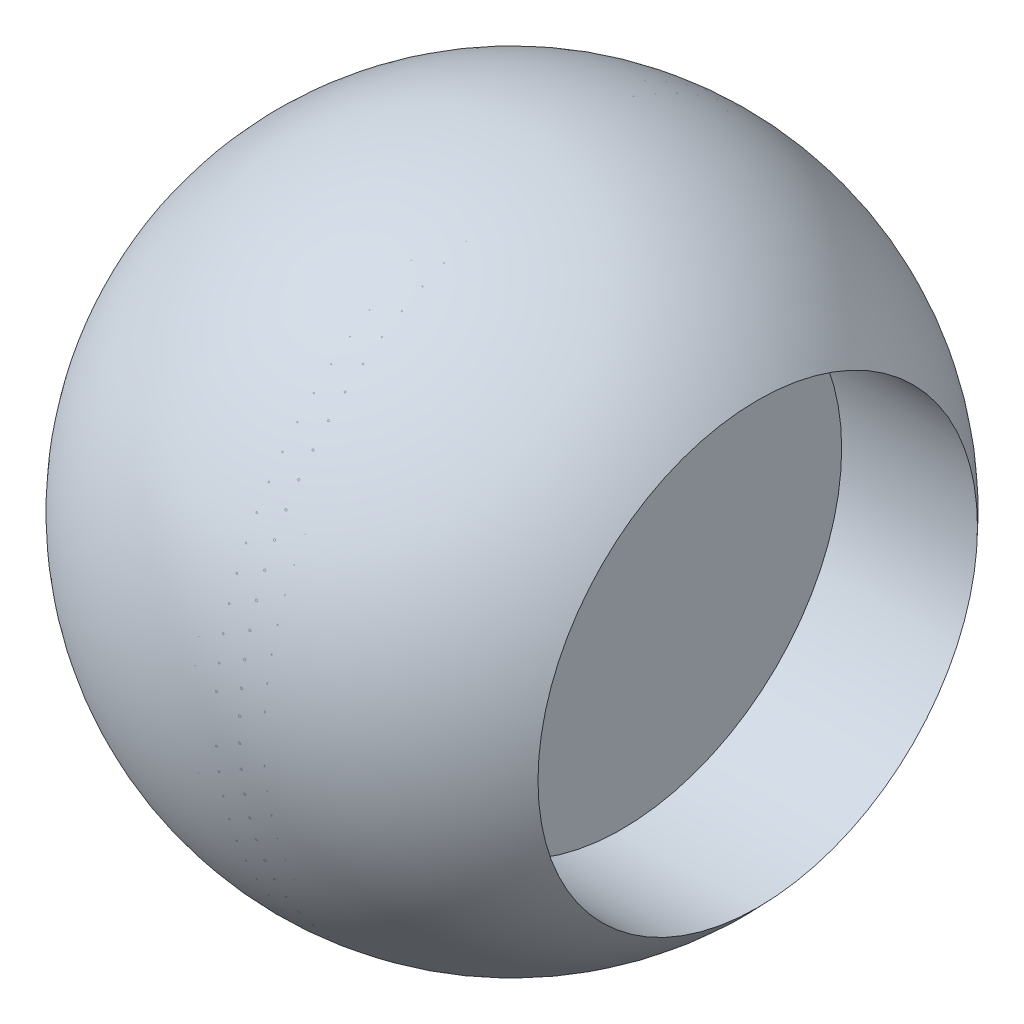
from build123d import *

# Parameters (mm, degrees)
SKETCH4_R          = 15
CUT_EXTRUDE1_DEPTH = 15


with BuildPart() as part:
    # Sketch1 → Revolve1 (revolve)
    with BuildSketch(Plane.XY):
        with BuildLine():
            Line((0, 22.5), (0, -22.5))
            ThreePointArc((0, -22.5), (22.5, 0), (0, 22.5))
        make_face()
    revolve(axis=Axis((0, 22.5, 0), (0, -1, 0)))

    # Sketch2 → Cut-Revolve6 (revolve, cut)
    with BuildSketch(Plane.XY):
        with BuildLine():
            Line((5, 19.917809385), (-5, 19.917809385))
            Line((-5, 19.917809385), (-5, 21.917809385))
            ThreePointArc((-5, 21.917809385), (0, 22.480888956), (5, 21.917809385))
            Line((5, 21.917809385), (5, 19.917809385))
        make_face()
    revolve(axis=Axis((0, 0, 0), (-1, 0, 0)), mode=Mode.SUBTRACT)

    # Sketch4 → Cut-Extrude1 (cut)
    with BuildSketch(Plane(origin=(22.5, 0, 0), x_dir=(0, 0, -1), z_dir=(1, 0, 0))):
        Circle(SKETCH4_R)
    extrude(amount=-CUT_EXTRUDE1_DEPTH, mode=Mode.SUBTRACT)


solid = part.part
